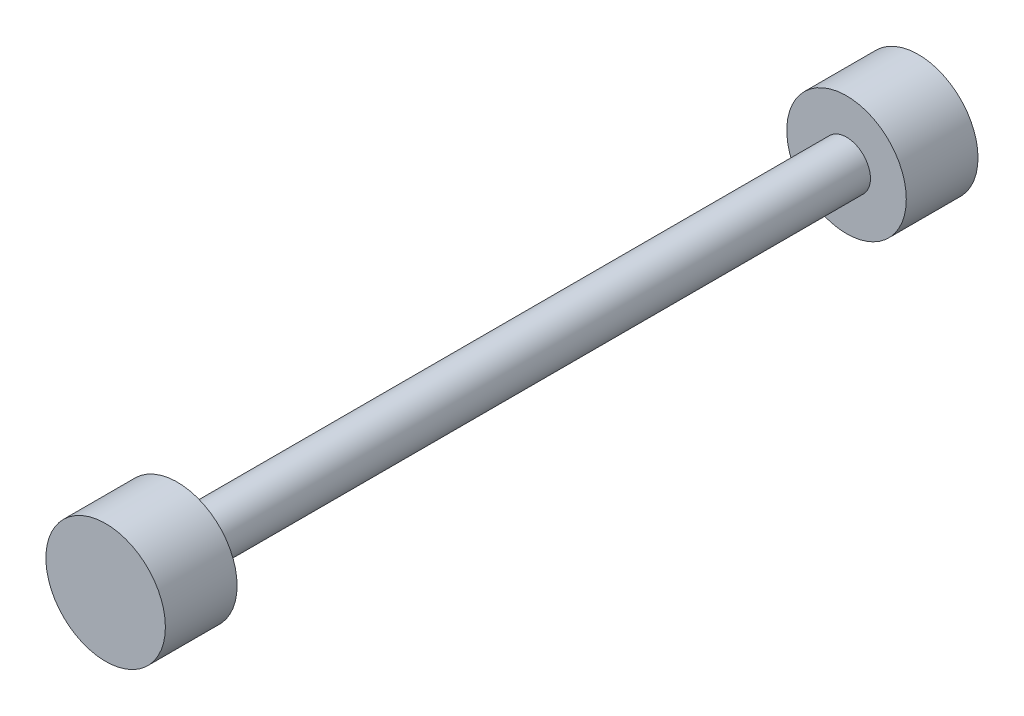
from build123d import *

# Parameters (mm, degrees)
SKETCH1_R           = 15.875
BOSS_EXTRUDE1_DEPTH = 19.05
SKETCH2_R           = 6.35
BOSS_EXTRUDE2_DEPTH = 177.8
SKETCH3_R           = 15.875
BOSS_EXTRUDE3_DEPTH = 19.05


with BuildPart() as part:
    # Sketch1 → Boss-Extrude1 (new body)
    with BuildSketch(Plane.XY):
        Circle(SKETCH1_R)
    extrude(amount=BOSS_EXTRUDE1_DEPTH)

    # Sketch2 → Boss-Extrude2 (add)
    with BuildSketch(Plane.XY.offset(19.05)):
        Circle(SKETCH2_R)
    extrude(amount=BOSS_EXTRUDE2_DEPTH)

    # Sketch3 → Boss-Extrude3 (add)
    with BuildSketch(Plane.XY.offset(196.85)):
        Circle(SKETCH3_R)
    extrude(amount=BOSS_EXTRUDE3_DEPTH)


solid = part.part
